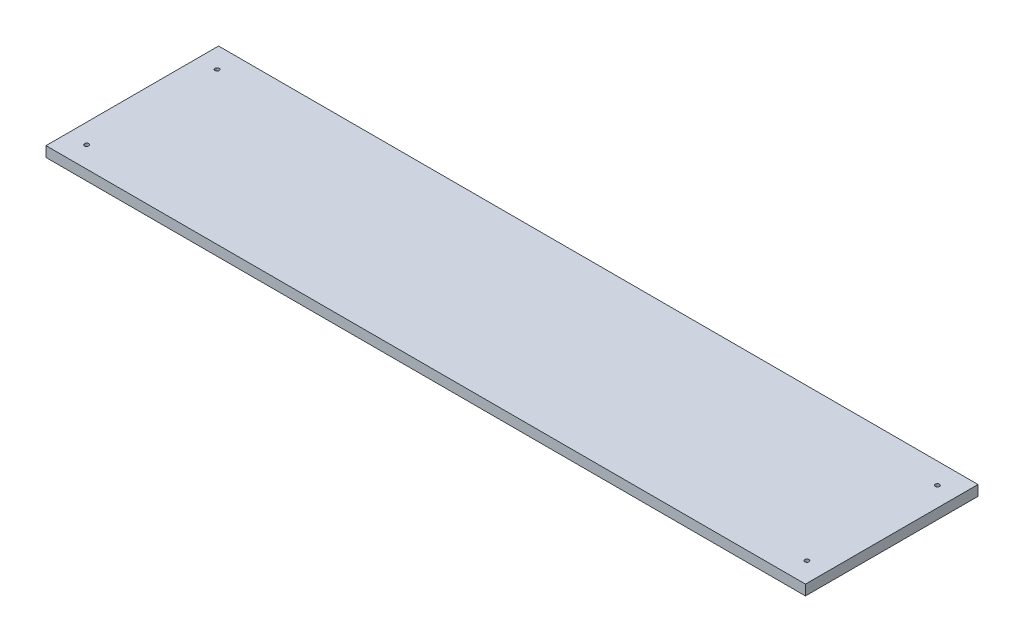
from build123d import *

# Parameters (mm, degrees)
SZKIC1_W                                   = 736.8
SZKIC1_H                                   = 167.4
DODANIE_WYCI_GNI_CIE1_DEPTH                = 10
SZKIC2_W                                   = 729.8
SZKIC2_H                                   = 160.4
SZKIC2_W_2                                 = 723.8
SZKIC2_H_2                                 = 154.4
WYCI_CIE_WYCI_GNI_CIE_CIENKA_CIANKA1_DEPTH = 3
SZKIC3_W                                   = 713.8
SZKIC3_H                                   = 144.4
WYTNIJ_WYCI_GNI_CIE1_DEPTH                 = 5
ZAOKR_GLENIE1_R                            = 3
SZKIC4_R                                   = 4
SZKIC4_R_2                                 = 2
DODANIE_WYCI_GNI_CIE2_DEPTH                = 10
SZKIC4_3_R                                 = 2
WYTNIJ_WYCI_GNI_CIE2_DEPTH                 = 10


with BuildPart() as part:
    # Szkic1 → Dodanie-wyci_gni_cie1 (new body)
    with BuildSketch(Plane(origin=(0, 0, 0), x_dir=(1, 0, 0), z_dir=(0, 1, 0))):
        with Locations((35.673743017, 109.761452514)):
            Rectangle(SZKIC1_W, SZKIC1_H)
    extrude(amount=DODANIE_WYCI_GNI_CIE1_DEPTH)

    # Szkic2 → Wyci_cie-wyci_gni_cie-cienka _cianka1 (cut)
    with BuildSketch(Plane.XZ):
        with Locations((35.673743017, -109.761452514)):
            Rectangle(SZKIC2_W, SZKIC2_H)
        with Locations((35.673743017, -109.761452514)):
            Rectangle(SZKIC2_W_2, SZKIC2_H_2, mode=Mode.SUBTRACT)
    extrude(amount=-WYCI_CIE_WYCI_GNI_CIE_CIENKA_CIANKA1_DEPTH, mode=Mode.SUBTRACT)

    # Szkic3 → Wytnij-wyci_gni_cie1 (cut)
    with BuildSketch(Plane.XZ):
        with Locations((35.673743017, -109.761452514)):
            Rectangle(SZKIC3_W, SZKIC3_H)
    extrude(amount=-WYTNIJ_WYCI_GNI_CIE1_DEPTH, mode=Mode.SUBTRACT)

    # Zaokr_glenie1
    zaokr_glenie1_edges = [part.edges().sort_by_distance(p)[0] for p in [
        (-321.226256983, 2.5, -181.961452514),
        (-329.226256983, 1.5, -189.961452514),
        (-329.226256983, 1.5, -29.561452514),
        (-326.226256983, 1.5, -32.561452514),
        (397.573743017, 1.5, -32.561452514),
        (400.573743017, 1.5, -29.561452514),
        (400.573743017, 1.5, -189.961452514),
        (397.573743017, 1.5, -186.961452514),
    ]]
    fillet(zaokr_glenie1_edges, radius=ZAOKR_GLENIE1_R)

    # Szkic4 → Dodanie-wyci_gni_cie2 (add)
    # profile 1 of 4: a face of its own
    with BuildSketch(Plane.XZ):
        with Locations((-313.726256983, -46.461452514)):
            Circle(SZKIC4_R)
    # profile 2 of 4: a face of its own
    with BuildSketch(Plane.XZ):
        with Locations((-313.726256983, -173.061452514)):
            Circle(SZKIC4_R)
        with Locations((-313.726256983, -173.061452514)):
            Circle(SZKIC4_R_2, mode=Mode.SUBTRACT)
    # profile 3 of 4: a face of its own
    with BuildSketch(Plane.XZ):
        with Locations((385.073743017, -173.061452514)):
            Circle(SZKIC4_R)
        with Locations((385.073743017, -173.061452514)):
            Circle(SZKIC4_R_2, mode=Mode.SUBTRACT)
    # profile 4 of 4: a face of its own
    with BuildSketch(Plane.XZ):
        with Locations((385.073743017, -46.461452514)):
            Circle(SZKIC4_R)
    extrude(amount=-DODANIE_WYCI_GNI_CIE2_DEPTH)

    # Szkic4_3 → Wytnij-wyci_gni_cie2 (cut)
    with BuildSketch(Plane.XZ):
        with Locations((-313.726256983, -46.461452514)):
            Circle(SZKIC4_3_R)
        with Locations((-313.726256983, -173.061452514)):
            Circle(SZKIC4_3_R)
        with Locations((385.073743017, -173.061452514)):
            Circle(SZKIC4_3_R)
        with Locations((385.073743017, -46.461452514)):
            Circle(SZKIC4_3_R)
    extrude(amount=-WYTNIJ_WYCI_GNI_CIE2_DEPTH, mode=Mode.SUBTRACT)


solid = part.part
